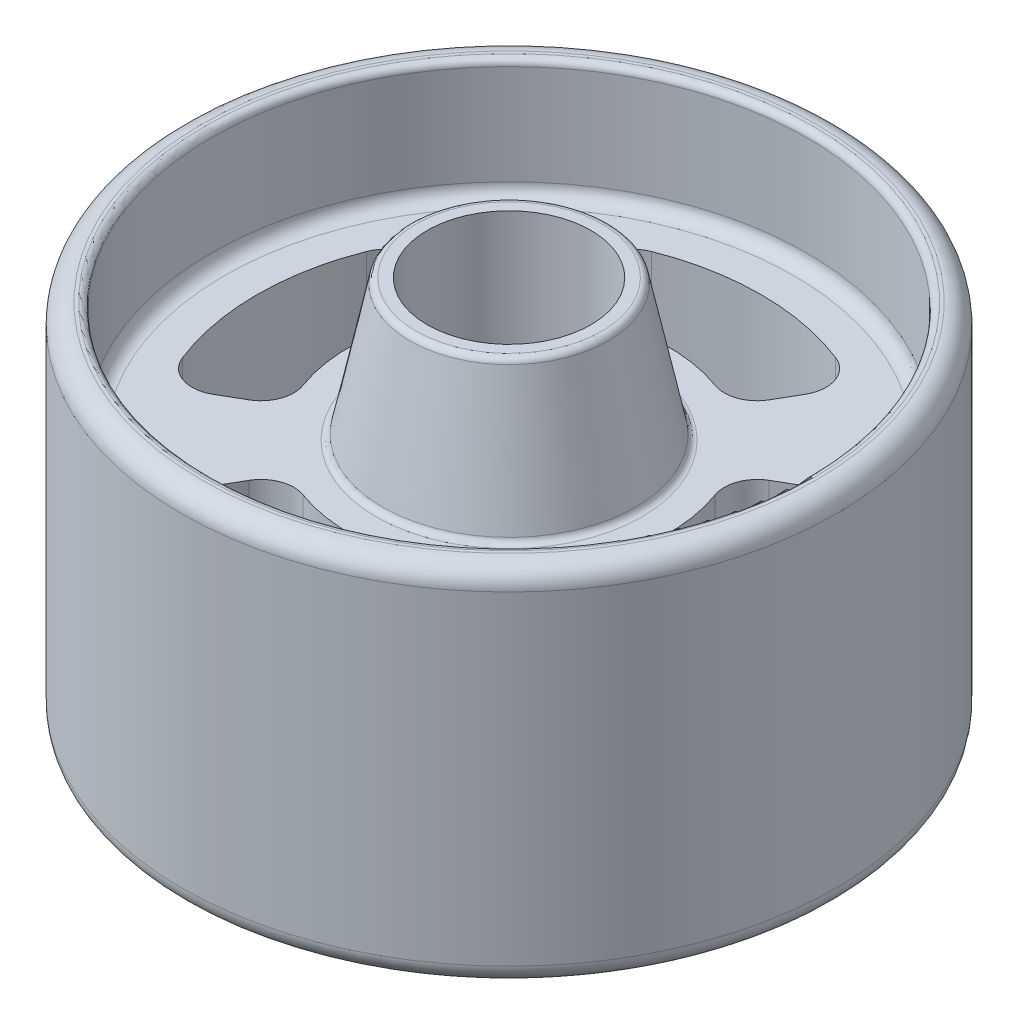
from build123d import *

# Parameters (mm, degrees)
SKETCH_1_R               = 50
EXTRUDE_1_DEPTH          = 4.75
SKETCH_2_R               = 12.5
CUT_EXTRUDE_1_DEPTH      = 5.75
CUT_EXTRUDE_1_DEPTH_BACK = 5.75
SKETCH_9_R               = 12.5
CUT_EXTRUDE_2_DEPTH      = 32
CUT_EXTRUDE_2_DEPTH_BACK = 32
FILLET_1_R               = 1


with BuildPart() as part:
    # 스케치1 → 보스-돌출1 (new body, symmetric)
    with BuildSketch(Plane(origin=(0, 0, 0), x_dir=(1, 0, 0), z_dir=(0, 1, 0))):
        Circle(SKETCH_1_R)
    extrude(amount=EXTRUDE_1_DEPTH, both=True)

    # 스케치2 → 컷-돌출1 (cut, two sides)
    with BuildSketch(Plane(origin=(0, 0, 0), x_dir=(1, 0, 0), z_dir=(0, 1, 0))) as cut_extrude_1_sk:
        Circle(SKETCH_2_R)
        with BuildLine():
            Line((-14.53659176, 25.178115497), (-16.562382075, 28.686887248))
            ThreePointArc((-16.562382075, 28.686887248), (-16.951495099, 32.838787189), (-14.057964766, 35.841646539))
            ThreePointArc((-14.057964766, 35.841646539), (0, 38.5), (14.057964766, 35.841646539))
            ThreePointArc((14.057964766, 35.841646539), (16.951495099, 32.838787189), (16.562382075, 28.686887248))
            Line((16.562382075, 28.686887248), (14.53659176, 25.178115497))
            ThreePointArc((14.53659176, 25.178115497), (11.906649739, 22.976055207), (8.476555463, 22.986909481))
            ThreePointArc((8.476555463, 22.986909481), (0, 24.5), (-8.476555463, 22.986909481))
            ThreePointArc((-8.476555463, 22.986909481), (-11.906649739, 22.976055207), (-14.53659176, 25.178115497))
        make_face()
        with BuildLine():
            Line((25.178115497, 14.53659176), (28.686887248, 16.562382075))
            ThreePointArc((28.686887248, 16.562382075), (32.838787189, 16.951495099), (35.841646539, 14.057964766))
            ThreePointArc((35.841646539, 14.057964766), (38.5, 0), (35.841646539, -14.057964766))
            ThreePointArc((35.841646539, -14.057964766), (32.838787189, -16.951495099), (28.686887248, -16.562382075))
            Line((28.686887248, -16.562382075), (25.178115497, -14.53659176))
            ThreePointArc((25.178115497, -14.53659176), (22.976055207, -11.906649739), (22.986909481, -8.476555463))
            ThreePointArc((22.986909481, -8.476555463), (24.5, 0), (22.986909481, 8.476555463))
            ThreePointArc((22.986909481, 8.476555463), (22.976055207, 11.906649739), (25.178115497, 14.53659176))
        make_face()
        with BuildLine():
            Line((14.53659176, -25.178115497), (16.562382075, -28.686887248))
            ThreePointArc((16.562382075, -28.686887248), (16.951495099, -32.838787189), (14.057964766, -35.841646539))
            ThreePointArc((14.057964766, -35.841646539), (0, -38.5), (-14.057964766, -35.841646539))
            ThreePointArc((-14.057964766, -35.841646539), (-16.951495099, -32.838787189), (-16.562382075, -28.686887248))
            Line((-16.562382075, -28.686887248), (-14.53659176, -25.178115497))
            ThreePointArc((-14.53659176, -25.178115497), (-11.906649739, -22.976055207), (-8.476555463, -22.986909481))
            ThreePointArc((-8.476555463, -22.986909481), (0, -24.5), (8.476555463, -22.986909481))
            ThreePointArc((8.476555463, -22.986909481), (11.906649739, -22.976055207), (14.53659176, -25.178115497))
        make_face()
        with BuildLine():
            Line((-25.178115497, -14.53659176), (-28.686887248, -16.562382075))
            ThreePointArc((-28.686887248, -16.562382075), (-32.838787189, -16.951495099), (-35.841646539, -14.057964766))
            ThreePointArc((-35.841646539, -14.057964766), (-38.5, 0), (-35.841646539, 14.057964766))
            ThreePointArc((-35.841646539, 14.057964766), (-32.838787189, 16.951495099), (-28.686887248, 16.562382075))
            Line((-28.686887248, 16.562382075), (-25.178115497, 14.53659176))
            ThreePointArc((-25.178115497, 14.53659176), (-22.976055207, 11.906649739), (-22.986909481, 8.476555463))
            ThreePointArc((-22.986909481, 8.476555463), (-24.5, 0), (-22.986909481, -8.476555463))
            ThreePointArc((-22.986909481, -8.476555463), (-22.976055207, -11.906649739), (-25.178115497, -14.53659176))
        make_face()
    extrude(amount=CUT_EXTRUDE_1_DEPTH, mode=Mode.SUBTRACT)
    extrude(cut_extrude_1_sk.sketch, amount=-CUT_EXTRUDE_1_DEPTH_BACK, mode=Mode.SUBTRACT)

    # 스케치4 → 회전1 (revolve)
    with BuildSketch(Plane.XY):
        with BuildLine():
            Line((12.5, 31), (14.187633366, 31))
            ThreePointArc((14.187633366, 31), (14.818163637, 30.776164658), (15.166423991, 30.204863154))
            Line((15.166423991, 30.204863154), (19.5, 9.5))
            Line((19.5, 9.5), (43.5, 9.5))
            ThreePointArc((43.5, 9.5), (44.914213562, 10.085786438), (45.5, 11.5))
            Line((45.5, 11.5), (45.5, 26.75))
            ThreePointArc((45.5, 26.75), (45.792893219, 27.457106781), (46.5, 27.75))
            Line((46.5, 27.75), (47, 27.75))
            ThreePointArc((47, 27.75), (49.121320344, 26.871320344), (50, 24.75))
            Line((50, 24.75), (50, 4.75))
            Line((50, 4.75), (12.5, 4.75))
            Line((12.5, 4.75), (12.5, 31))
        make_face()
    revolve_1 = revolve(axis=Axis((0, 4.75, 0), (0, -1, 0)))

    # 대칭 복사1: 회전1 across plane
    add(revolve_1.mirror(Plane.ZX))

    # 스케치9 → 컷-돌출2 (cut, two sides)
    with BuildSketch(Plane(origin=(0, 0, 0), x_dir=(1, 0, 0), z_dir=(0, 1, 0))) as cut_extrude_2_sk:
        Circle(SKETCH_9_R)
        with BuildLine():
            Line((-14.53659176, 25.178115497), (-16.562382075, 28.686887248))
            ThreePointArc((-16.562382075, 28.686887248), (-16.951495099, 32.838787189), (-14.057964766, 35.841646539))
            ThreePointArc((-14.057964766, 35.841646539), (0, 38.5), (14.057964766, 35.841646539))
            ThreePointArc((14.057964766, 35.841646539), (16.951495099, 32.838787189), (16.562382075, 28.686887248))
            Line((16.562382075, 28.686887248), (14.53659176, 25.178115497))
            ThreePointArc((14.53659176, 25.178115497), (11.906649739, 22.976055207), (8.476555463, 22.986909481))
            ThreePointArc((8.476555463, 22.986909481), (0, 24.5), (-8.476555463, 22.986909481))
            ThreePointArc((-8.476555463, 22.986909481), (-11.906649739, 22.976055207), (-14.53659176, 25.178115497))
        make_face()
        with BuildLine():
            Line((25.178115497, 14.53659176), (28.686887248, 16.562382075))
            ThreePointArc((28.686887248, 16.562382075), (32.838787189, 16.951495099), (35.841646539, 14.057964766))
            ThreePointArc((35.841646539, 14.057964766), (38.5, 0), (35.841646539, -14.057964766))
            ThreePointArc((35.841646539, -14.057964766), (32.838787189, -16.951495099), (28.686887248, -16.562382075))
            Line((28.686887248, -16.562382075), (25.178115497, -14.53659176))
            ThreePointArc((25.178115497, -14.53659176), (22.976055207, -11.906649739), (22.986909481, -8.476555463))
            ThreePointArc((22.986909481, -8.476555463), (24.5, 0), (22.986909481, 8.476555463))
            ThreePointArc((22.986909481, 8.476555463), (22.976055207, 11.906649739), (25.178115497, 14.53659176))
        make_face()
        with BuildLine():
            Line((14.53659176, -25.178115497), (16.562382075, -28.686887248))
            ThreePointArc((16.562382075, -28.686887248), (16.951495099, -32.838787189), (14.057964766, -35.841646539))
            ThreePointArc((14.057964766, -35.841646539), (0, -38.5), (-14.057964766, -35.841646539))
            ThreePointArc((-14.057964766, -35.841646539), (-16.951495099, -32.838787189), (-16.562382075, -28.686887248))
            Line((-16.562382075, -28.686887248), (-14.53659176, -25.178115497))
            ThreePointArc((-14.53659176, -25.178115497), (-11.906649739, -22.976055207), (-8.476555463, -22.986909481))
            ThreePointArc((-8.476555463, -22.986909481), (0, -24.5), (8.476555463, -22.986909481))
            ThreePointArc((8.476555463, -22.986909481), (11.906649739, -22.976055207), (14.53659176, -25.178115497))
        make_face()
        with BuildLine():
            Line((-25.178115497, -14.53659176), (-28.686887248, -16.562382075))
            ThreePointArc((-28.686887248, -16.562382075), (-32.838787189, -16.951495099), (-35.841646539, -14.057964766))
            ThreePointArc((-35.841646539, -14.057964766), (-38.5, 0), (-35.841646539, 14.057964766))
            ThreePointArc((-35.841646539, 14.057964766), (-32.838787189, 16.951495099), (-28.686887248, 16.562382075))
            Line((-28.686887248, 16.562382075), (-25.178115497, 14.53659176))
            ThreePointArc((-25.178115497, 14.53659176), (-22.976055207, 11.906649739), (-22.986909481, 8.476555463))
            ThreePointArc((-22.986909481, 8.476555463), (-24.5, 0), (-22.986909481, -8.476555463))
            ThreePointArc((-22.986909481, -8.476555463), (-22.976055207, -11.906649739), (-25.178115497, -14.53659176))
        make_face()
    extrude(amount=CUT_EXTRUDE_2_DEPTH, mode=Mode.SUBTRACT)
    extrude(cut_extrude_2_sk.sketch, amount=-CUT_EXTRUDE_2_DEPTH_BACK, mode=Mode.SUBTRACT)

    # 필렛1
    fillet_1_edges = [part.edges().sort_by_distance(p)[0] for p in [
        (-19.5, 9.5, 0),
        (-19.5, -9.5, 0),
    ]]
    fillet(fillet_1_edges, radius=FILLET_1_R)


solid = part.part
